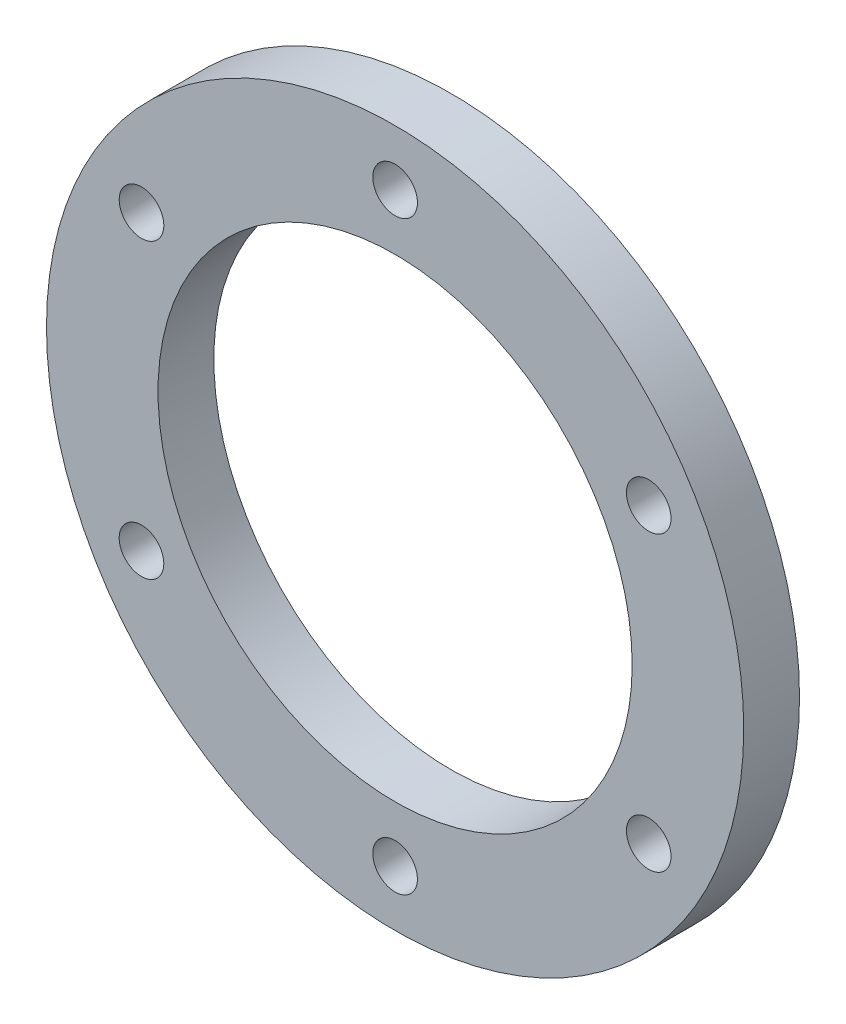
from build123d import *

# Parameters (mm, degrees)
SKETCH1_R          = 62.5
SKETCH1_R_2        = 42.5
BODY_DEPTH         = 5
SKETCH2_R          = 4
CUT_EXTRUDE1_DEPTH = 11
HOLES_COUNT        = 6


with BuildPart() as part:
    # Sketch1 → Body (new body, symmetric)
    with BuildSketch(Plane.XY):
        Circle(SKETCH1_R)
        Circle(SKETCH1_R_2, mode=Mode.SUBTRACT)
    extrude(amount=BODY_DEPTH, both=True)

    # Sketch2 → Cut-Extrude1 (cut, through all)
    with BuildSketch(Plane.XY.offset(5)):
        with Locations((0, 52.5)):
            Circle(SKETCH2_R)
    cut_extrude1 = extrude(amount=-CUT_EXTRUDE1_DEPTH, mode=Mode.SUBTRACT)

    # Holes: Cut-Extrude1 ×6 about axis
    holes_axis = Axis((0, 0, 0), (0, 0, 1))
    for i in range(1, HOLES_COUNT):
        add(cut_extrude1.rotate(holes_axis, i * 360 / HOLES_COUNT), mode=Mode.SUBTRACT)


solid = part.part
